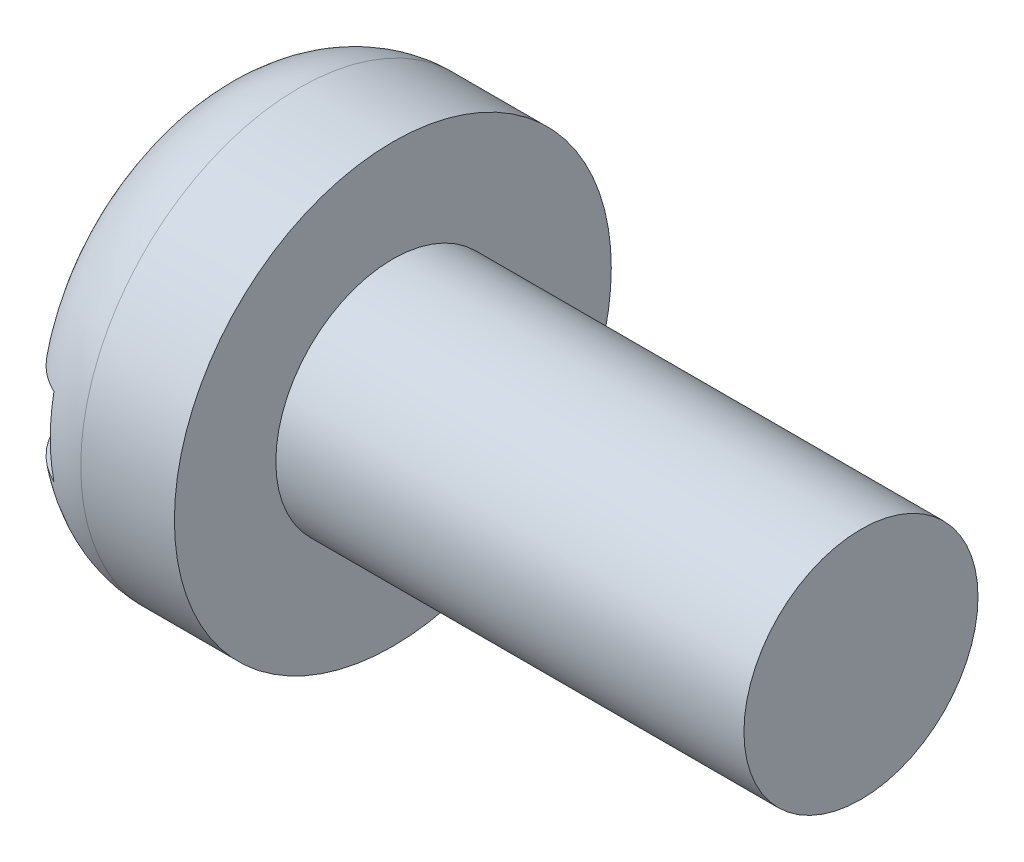
from build123d import *

# Parameters (mm, degrees)
SKETCH2_W  = 5.6
SKETCH2_H  = 1
SLOT_DEPTH = 0.7


with BuildPart() as part:
    # BodySke → Base-Revolve (revolve)
    with BuildSketch(Plane.XY):
        with BuildLine():
            Line((2.4, 1.5), (2.4, 2.8))
            Line((2.4, 2.8), (1.2, 2.8))
            ThreePointArc((1.2, 2.8), (0.351471863, 2.448528137), (0, 1.6))
            Line((0, 1.6), (0, 0))
            Line((0, 0), (8.4, 0))
            Line((8.4, 0), (8.4, 1.5))
            Line((8.4, 1.5), (2.4, 1.5))
        make_face()
    revolve(axis=Axis((-25.4, 0, 0), (1, 0, 0)))

    # Sketch2 → Slot (cut)
    with BuildSketch(Plane(origin=(0, 0, 0), x_dir=(0, 0, -1), z_dir=(1, 0, 0))):
        Rectangle(SKETCH2_W, SKETCH2_H)
    extrude(amount=SLOT_DEPTH, mode=Mode.SUBTRACT)


solid = part.part
